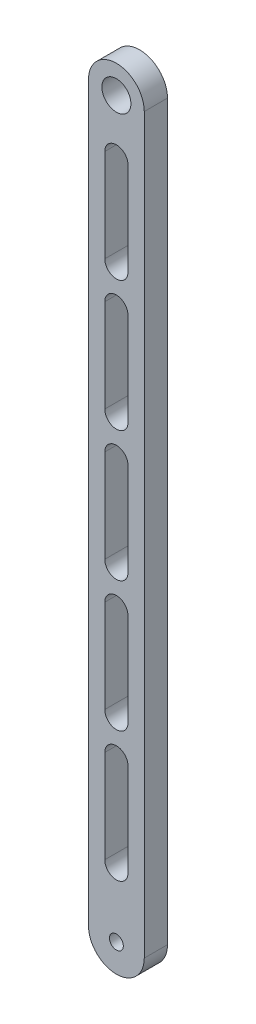
from build123d import *

# Parameters (mm, degrees)
SKETCH_2_R             = 3.96748
EXTRUDE_1_DEPTH        = 6.35
F_10_24_TAPPED_HOLE1_D = 3.7973


with BuildPart() as part:
    # 草图2 → 凸台-拉伸1 (new body)
    with BuildSketch(Plane.XY):
        with BuildLine():
            Line((-7.62, 0), (-7.62, 200.3806))
            ThreePointArc((-7.62, 200.3806), (0, 208.0006), (7.62, 200.3806))
            Line((7.62, 200.3806), (7.62, 0))
            ThreePointArc((7.62, 0), (0, -7.62), (-7.62, 0))
        make_face()
        with Locations((0, 200.3806)):
            Circle(SKETCH_2_R, mode=Mode.SUBTRACT)
        with BuildLine():
            Line((3.175, 185.5216), (3.175, 160.1216))
            ThreePointArc((3.175, 160.1216), (0, 156.9466), (-3.175, 160.1216))
            Line((-3.175, 160.1216), (-3.175, 185.5216))
            ThreePointArc((-3.175, 185.5216), (0, 188.6966), (3.175, 185.5216))
        make_face(mode=Mode.SUBTRACT)
        with BuildLine():
            Line((3.175, 149.9616), (3.175, 124.5616))
            ThreePointArc((3.175, 124.5616), (0, 121.3866), (-3.175, 124.5616))
            Line((-3.175, 124.5616), (-3.175, 149.9616))
            ThreePointArc((-3.175, 149.9616), (0, 153.1366), (3.175, 149.9616))
        make_face(mode=Mode.SUBTRACT)
        with BuildLine():
            Line((3.175, 114.4016), (3.175, 89.0016))
            ThreePointArc((3.175, 89.0016), (0, 85.8266), (-3.175, 89.0016))
            Line((-3.175, 89.0016), (-3.175, 114.4016))
            ThreePointArc((-3.175, 114.4016), (0, 117.5766), (3.175, 114.4016))
        make_face(mode=Mode.SUBTRACT)
        with BuildLine():
            Line((3.175, 78.8416), (3.175, 53.4416))
            ThreePointArc((3.175, 53.4416), (0, 50.2666), (-3.175, 53.4416))
            Line((-3.175, 53.4416), (-3.175, 78.8416))
            ThreePointArc((-3.175, 78.8416), (0, 82.0166), (3.175, 78.8416))
        make_face(mode=Mode.SUBTRACT)
        with BuildLine():
            Line((3.175, 43.2816), (3.175, 17.8816))
            ThreePointArc((3.175, 17.8816), (0, 14.7066), (-3.175, 17.8816))
            Line((-3.175, 17.8816), (-3.175, 43.2816))
            ThreePointArc((-3.175, 43.2816), (0, 46.4566), (3.175, 43.2816))
        make_face(mode=Mode.SUBTRACT)
    extrude(amount=EXTRUDE_1_DEPTH)

    # #10-24 Tapped Hole1 (through all)
    with Locations(Plane.XY.offset(6.35)):
        with Locations((0, 0)):
            Hole(F_10_24_TAPPED_HOLE1_D / 2)


solid = part.part
